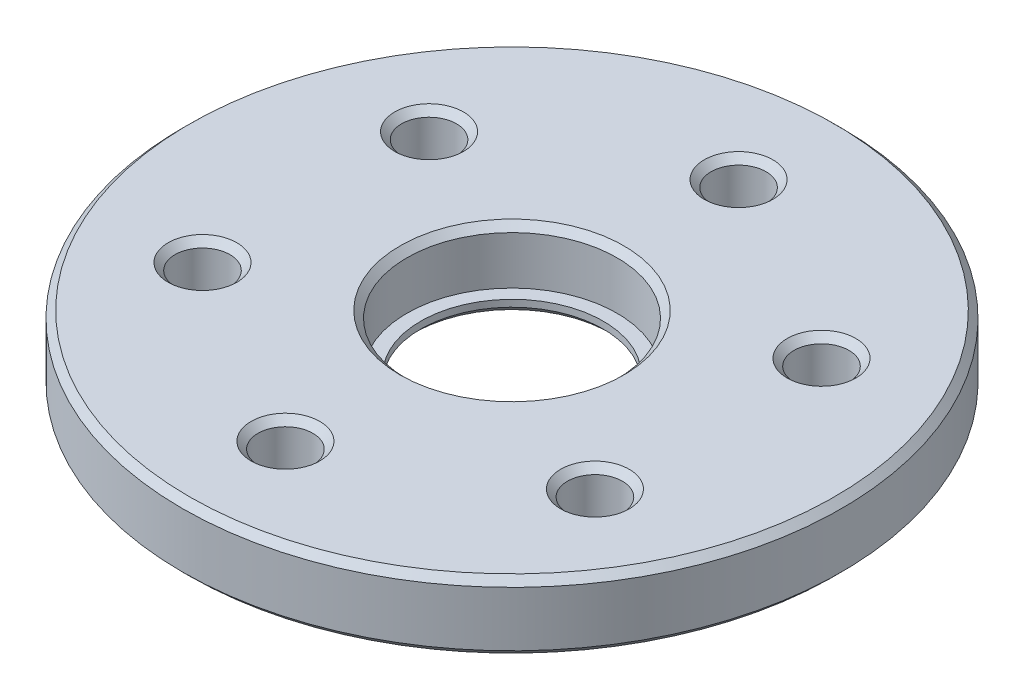
from build123d import *

# Parameters (mm, degrees)
SKETCH1_R           = 24
SKETCH1_R_2         = 7.65
BOSS_EXTRUDE1_DEPTH = 4
SKETCH2_R           = 2
CUT_EXTRUDE1_DEPTH  = 5
CIRPATTERN2_COUNT   = 6
SKETCH3_R           = 24
SKETCH3_R_2         = 6.65
SKETCH3_R_3         = 2
BOSS_EXTRUDE2_DEPTH = 1
CHAMFER1_SIZE       = 0.5


with BuildPart() as part:
    # Sketch1 → Boss-Extrude1 (new body)
    with BuildSketch(Plane(origin=(0, 0, 0), x_dir=(1, 0, 0), z_dir=(0, 1, 0))):
        Circle(SKETCH1_R)
        Circle(SKETCH1_R_2, mode=Mode.SUBTRACT)
    extrude(amount=BOSS_EXTRUDE1_DEPTH)

    # Sketch2 → Cut-Extrude1 (cut, through all)
    with BuildSketch(Plane(origin=(0, 4, 0), x_dir=(1, 0, 0), z_dir=(0, 1, 0))):
        with Locations((0, 16.5)):
            Circle(SKETCH2_R)
    cut_extrude1 = extrude(amount=-CUT_EXTRUDE1_DEPTH, mode=Mode.SUBTRACT)

    # CirPattern2: Cut-Extrude1 ×6 about axis
    cirpattern2_axis = Axis((0, 0, 0), (0, 1, 0))
    for i in range(1, CIRPATTERN2_COUNT):
        add(cut_extrude1.rotate(cirpattern2_axis, i * 360 / CIRPATTERN2_COUNT), mode=Mode.SUBTRACT)

    # Sketch3 → Boss-Extrude2 (add)
    with BuildSketch(Plane(origin=(0, 0, 0), x_dir=(1, 0, 0), z_dir=(0, 1, 0))):
        Circle(SKETCH3_R)
        Circle(SKETCH3_R_2, mode=Mode.SUBTRACT)
        with Locations((-14.289419, -8.25)):
            Circle(SKETCH3_R_3, mode=Mode.SUBTRACT)
        with Locations((0, -16.5)):
            Circle(SKETCH3_R_3, mode=Mode.SUBTRACT)
        with Locations((14.289419, -8.25)):
            Circle(SKETCH3_R_3, mode=Mode.SUBTRACT)
        with Locations((14.289419, 8.25)):
            Circle(SKETCH3_R_3, mode=Mode.SUBTRACT)
        with Locations((0, 16.5)):
            Circle(SKETCH3_R_3, mode=Mode.SUBTRACT)
        with Locations((-14.289419, 8.25)):
            Circle(SKETCH3_R_3, mode=Mode.SUBTRACT)
    extrude(amount=-BOSS_EXTRUDE2_DEPTH)

    # Chamfer1
    chamfer1_edges = [part.edges().sort_by_distance(p)[0] for p in [
        (-2, 4, -16.5),
        (13.289419, 4, -9.982051),
        (15.289419, 4, 6.517949),
        (2, 4, 16.5),
        (-13.289419, 4, 9.982051),
        (-15.289419, 4, -6.517949),
        (-24, -1, 0),
        (-16.289419, -1, -8.25),
        (-2, -1, -16.5),
        (12.289419, -1, -8.25),
        (12.289419, -1, 8.25),
        (-2, -1, 16.5),
        (-6.65, -1, 0),
        (-16.289419, -1, 8.25),
        (-24, 4, 0),
        (-7.65, 4, 0),
    ]]
    chamfer(chamfer1_edges, length=CHAMFER1_SIZE)


solid = part.part
